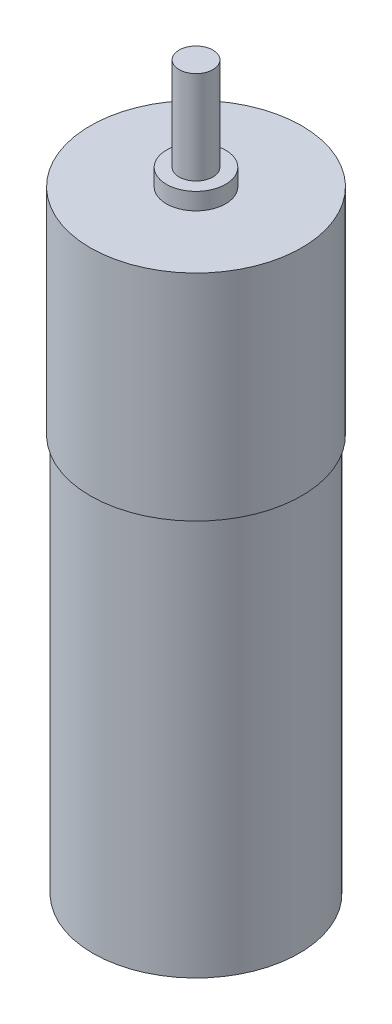
from build123d import *

# Parameters (mm, degrees)
SKETCH1_R           = 12.2
BOSS_EXTRUDE1_DEPTH = 47
SKETCH2_R           = 12.5
BOSS_EXTRUDE2_DEPTH = 25.4
SKETCH3_R           = 3.5
BOSS_EXTRUDE3_DEPTH = 2
SKETCH4_R           = 2
BOSS_EXTRUDE4_DEPTH = 11


with BuildPart() as part:
    # Sketch1 → Boss-Extrude1 (new body)
    with BuildSketch(Plane(origin=(0, 0, 0), x_dir=(1, 0, 0), z_dir=(0, 1, 0))):
        Circle(SKETCH1_R)
    extrude(amount=BOSS_EXTRUDE1_DEPTH)

    # Sketch2 → Boss-Extrude2 (add)
    with BuildSketch(Plane(origin=(0, 47, 0), x_dir=(1, 0, 0), z_dir=(0, 1, 0))):
        Circle(SKETCH2_R)
    extrude(amount=BOSS_EXTRUDE2_DEPTH)

    # Sketch3 → Boss-Extrude3 (add)
    with BuildSketch(Plane(origin=(0, 72.4, 0), x_dir=(1, 0, 0), z_dir=(0, 1, 0))):
        Circle(SKETCH3_R)
    extrude(amount=BOSS_EXTRUDE3_DEPTH)

    # Sketch4 → Boss-Extrude4 (add)
    with BuildSketch(Plane(origin=(0, 74.4, 0), x_dir=(1, 0, 0), z_dir=(0, 1, 0))):
        Circle(SKETCH4_R)
    extrude(amount=BOSS_EXTRUDE4_DEPTH)


solid = part.part
